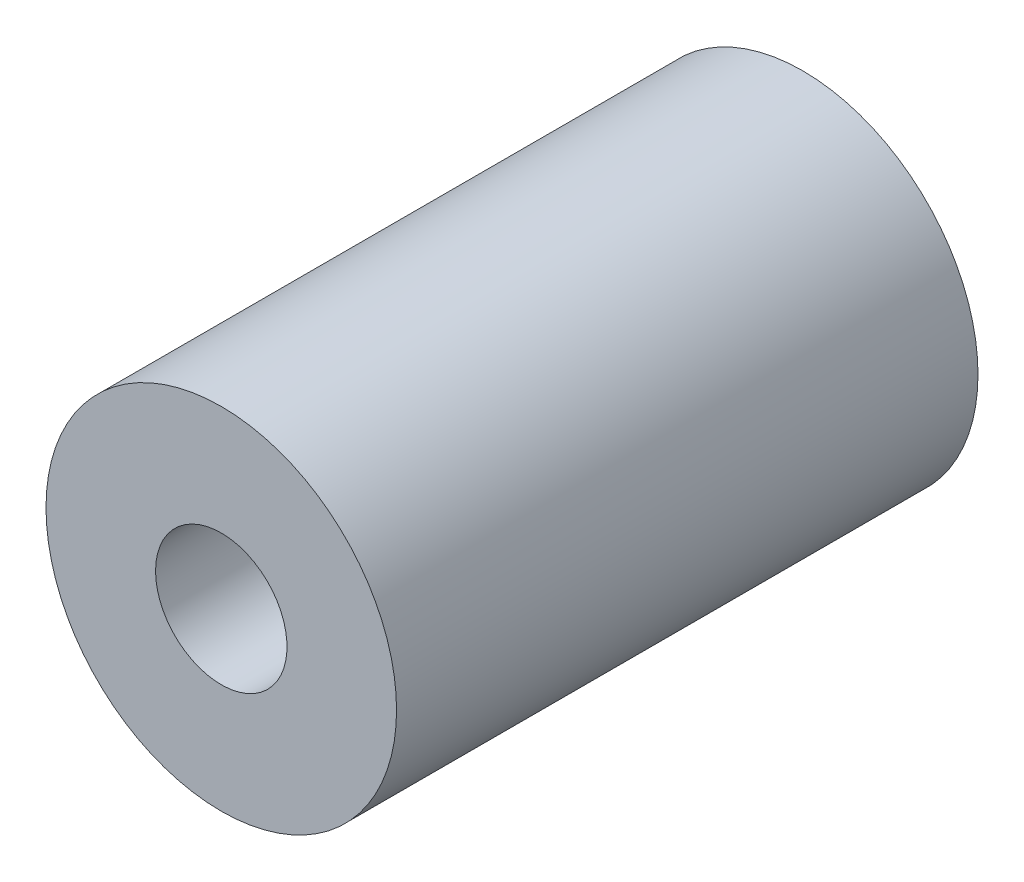
from build123d import *

# Parameters (mm, degrees)
ESQUISSE1_R             = 3
ESQUISSE1_R_2           = 1.125
BOSS_EXTRU_2_DEPTH      = 5
BOSS_EXTRU_2_DEPTH_BACK = 4.951754


with BuildPart() as part:
    # Esquisse1 → Boss.-Extru.2 (new body, two sides)
    with BuildSketch(Plane.XY) as boss_extru_2_sk:
        Circle(ESQUISSE1_R)
        Circle(ESQUISSE1_R_2, mode=Mode.SUBTRACT)
    extrude(amount=BOSS_EXTRU_2_DEPTH)
    extrude(boss_extru_2_sk.sketch, amount=-BOSS_EXTRU_2_DEPTH_BACK)


solid = part.part
